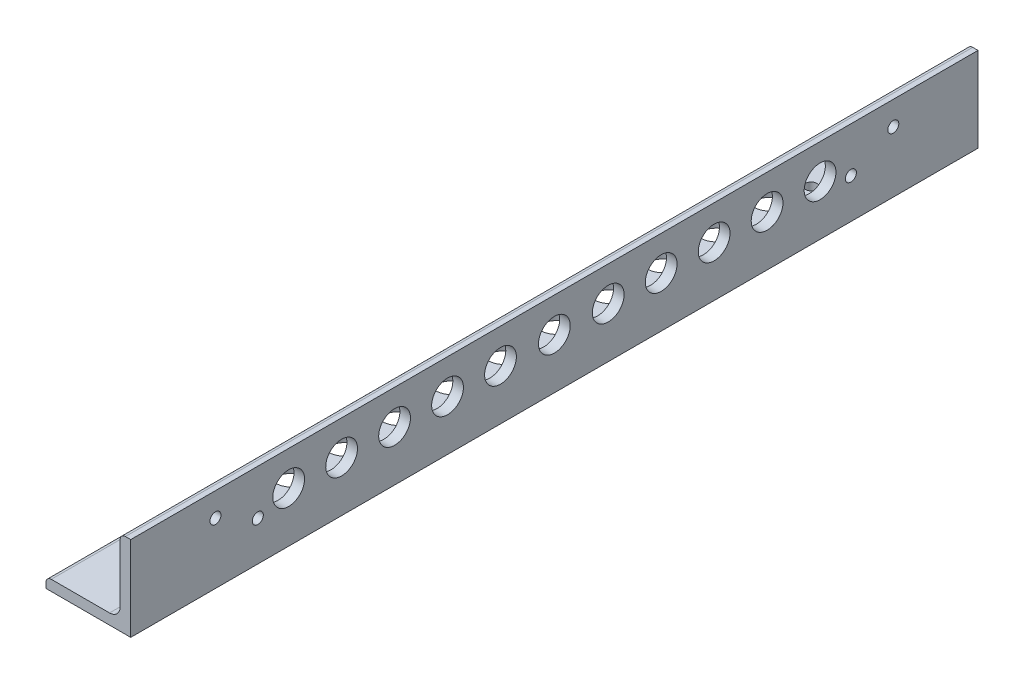
from build123d import *

# Parameters (mm, degrees)
BOSS_EXTRUDE1_DEPTH = 127
SKETCH4_R           = 1.651
SKETCH4_R_2         = 4.7625
CUT_EXTRUDE1_DEPTH  = 130.554006596
SKETCH5_R           = 1.651
SKETCH5_R_2         = 4.7625
CUT_EXTRUDE2_DEPTH  = 130.554006596


with BuildPart() as part:
    # Sketch2 → Boss-Extrude1 (new, symmetric)
    with BuildSketch(Plane.XY):
        with BuildLine():
            Line((-12.7, -12.7), (12.7, -12.7))
            Line((12.7, -12.7), (12.7, 12.7))
            Line((12.7, 12.7), (11.1125, 12.7))
            ThreePointArc((11.1125, 12.7), (9.989967985, 12.235032015), (9.525, 11.1125))
            Line((9.525, 11.1125), (9.525, -6.35))
            ThreePointArc((9.525, -6.35), (8.59506403, -8.59506403), (6.35, -9.525))
            Line((6.35, -9.525), (-11.1125, -9.525))
            ThreePointArc((-11.1125, -9.525), (-12.235032015, -9.989967985), (-12.7, -11.1125))
            Line((-12.7, -11.1125), (-12.7, -12.7))
        make_face()
    extrude(amount=BOSS_EXTRUDE1_DEPTH, both=True)

    # Sketch4 → Cut-Extrude1 (cut, through all)
    with BuildSketch(Plane(origin=(0, -9.525, 0), x_dir=(1, 0, 0), z_dir=(0, 1, 0))):
        with Locations(Location((-5.55625, 101.6, 0), (0, 0, 180))):
            Circle(SKETCH4_R)
        with Locations(Location((0.79375, 88.907891862, 0), (0, 0, 180))):
            Circle(SKETCH4_R)
        with Locations((0.79375, -88.907891862)):
            Circle(SKETCH4_R)
        with Locations((-5.55625, -101.6)):
            Circle(SKETCH4_R)
        with Locations(Location((-2.38125, 79.662291862, 0), (0, 0, 180))):
            Circle(SKETCH4_R_2)
        with Locations(Location((-2.38125, 63.660291862, 0), (0, 0, 180))):
            Circle(SKETCH4_R_2)
        with Locations(Location((-2.38125, 47.658291862, 0), (0, 0, 180))):
            Circle(SKETCH4_R_2)
        with Locations(Location((-2.38125, 31.656291862, 0), (0, 0, 180))):
            Circle(SKETCH4_R_2)
        with Locations(Location((-2.38125, 15.654291862, 0), (0, 0, 180))):
            Circle(SKETCH4_R_2)
        with Locations(Location((-2.38125, 0, 0), (0, 0, 180))):
            Circle(SKETCH4_R_2)
        with Locations(Location((-2.38125, -15.654291862, 0), (0, 0, 180))):
            Circle(SKETCH4_R_2)
        with Locations(Location((-2.38125, -31.656291862, 0), (0, 0, 180))):
            Circle(SKETCH4_R_2)
        with Locations(Location((-2.38125, -47.658291862, 0), (0, 0, 180))):
            Circle(SKETCH4_R_2)
        with Locations((-2.38125, -63.660291862)):
            Circle(SKETCH4_R_2)
        with Locations((-2.38125, -79.662291862)):
            Circle(SKETCH4_R_2)
    extrude(amount=-CUT_EXTRUDE1_DEPTH, mode=Mode.SUBTRACT)

    # Sketch5 → Cut-Extrude2 (cut, through all)
    with BuildSketch(Plane.ZY.offset(-9.525)):
        with Locations(Location((-88.9, -0.79375, 0), (0, 0, 270))):
            Circle(SKETCH5_R)
        with Locations(Location((-101.6, 5.55625, 0), (0, 0, 270))):
            Circle(SKETCH5_R)
        with Locations(Location((88.9, -0.79375, 0), (0, 0, 90))):
            Circle(SKETCH5_R)
        with Locations(Location((101.6, 5.55625, 0), (0, 0, 90))):
            Circle(SKETCH5_R)
        with Locations(Location((-79.650437411, 2.38125, 0), (0, 0, 270))):
            Circle(SKETCH5_R_2)
        with Locations(Location((-63.775437411, 2.38125, 0), (0, 0, 270))):
            Circle(SKETCH5_R_2)
        with Locations(Location((-47.900437411, 2.38125, 0), (0, 0, 270))):
            Circle(SKETCH5_R_2)
        with Locations(Location((-32.025437411, 2.38125, 0), (0, 0, 270))):
            Circle(SKETCH5_R_2)
        with Locations(Location((-16.150437411, 2.38125, 0), (0, 0, 270))):
            Circle(SKETCH5_R_2)
        with Locations(Location((0, 2.38125, 0), (0, 0, 270))):
            Circle(SKETCH5_R_2)
        with Locations(Location((16.150437411, 2.38125, 0), (0, 0, 90))):
            Circle(SKETCH5_R_2)
        with Locations(Location((32.025437411, 2.38125, 0), (0, 0, 90))):
            Circle(SKETCH5_R_2)
        with Locations(Location((47.900437411, 2.38125, 0), (0, 0, 90))):
            Circle(SKETCH5_R_2)
        with Locations(Location((63.775437411, 2.38125, 0), (0, 0, 90))):
            Circle(SKETCH5_R_2)
        with Locations(Location((79.650437411, 2.38125, 0), (0, 0, 90))):
            Circle(SKETCH5_R_2)
    extrude(amount=-CUT_EXTRUDE2_DEPTH, mode=Mode.SUBTRACT)


solid = part.part
